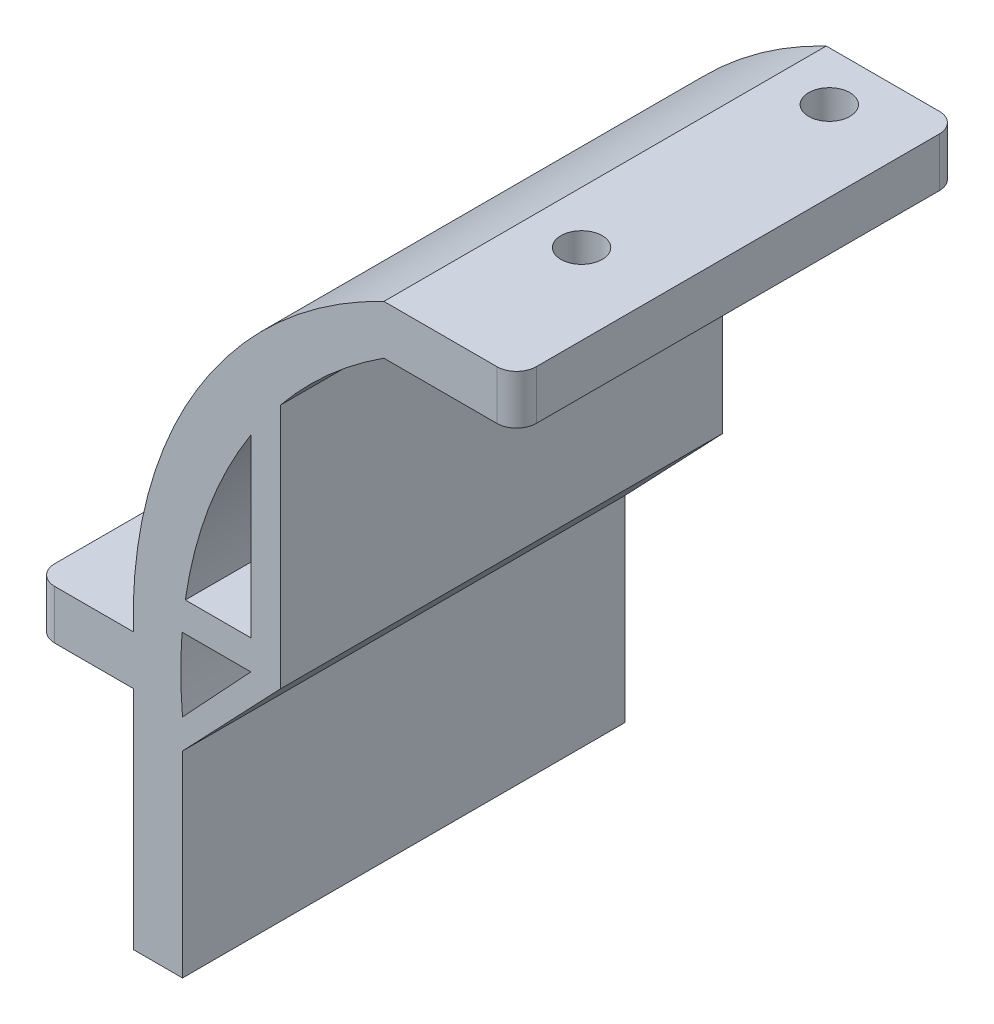
from build123d import *

# Parameters (mm, degrees)
SKETCH3_W           = 13.5
SKETCH3_H           = 5
SKETCH3_W_2         = 10
SKETCH3_W_3         = 5
SKETCH3_H_2         = 23
BOSS_EXTRUDE1_DEPTH = 45
FILLET1_R           = 2
SKETCH5_R           = 2.1
CUT_EXTRUDE2_DEPTH  = 45
SKETCH6_R           = 2.1
CUT_EXTRUDE3_DEPTH  = 45
SKETCH7_W           = 8.210459319
SKETCH7_H           = 32.58724939
BOSS_EXTRUDE2_DEPTH = 5
SKETCH8_R           = 2.1
CUT_EXTRUDE5_DEPTH  = 45
BOSS_EXTRUDE3_DEPTH = 45


with BuildPart() as part:
    # Sketch3 → Boss-Extrude1 (new body)
    with BuildSketch(Plane.XY):
        with BuildLine():
            ThreePointArc((-5.06519953, 257.264696919), (-21.146881422, 239.197551787), (-25.551614771, 215.414352888))
            Line((-25.551614771, 215.414352888), (-30.551614771, 215.414352888))
            Line((-30.551614771, 215.414352888), (-30.551614771, 220.414352888))
            ThreePointArc((-30.551614771, 220.414352888), (-24.004098535, 245.112635185), (-5.06519953, 262.264696919))
            Line((-5.06519953, 262.264696919), (-5.06519953, 257.264696919))
        make_face()
        with Locations((1.68480047, 259.764696919)):
            Rectangle(SKETCH3_W, SKETCH3_H)
        with Locations((-35.551614771, 217.914352888)):
            Rectangle(SKETCH3_W_2, SKETCH3_H)
        with Locations((-28.051614771, 203.914352888)):
            Rectangle(SKETCH3_W_3, SKETCH3_H_2)
    extrude(amount=BOSS_EXTRUDE1_DEPTH)

    # Fillet1
    fillet1_edges = [part.edges().sort_by_distance(p)[0] for p in [
        (-40.551614771, 217.914352888, 0),
        (8.43480047, 259.764696919, 45),
        (8.43480047, 259.764696919, 0),
        (-40.551614771, 217.914352888, 45),
    ]]
    fillet(fillet1_edges, radius=FILLET1_R)

    # Sketch5 → Cut-Extrude2 (cut)
    with BuildSketch(Plane(origin=(0, 262.264696919, 0), x_dir=(1, 0, 0), z_dir=(0, 1, 0))):
        with Locations((0.24480047, -40)):
            Circle(SKETCH5_R)
        with Locations((0.24480047, -14.8)):
            Circle(SKETCH5_R)
    extrude(amount=-CUT_EXTRUDE2_DEPTH, mode=Mode.SUBTRACT)

    # Sketch6 → Cut-Extrude3 (cut)
    with BuildSketch(Plane(origin=(0, 220.414352888, 0), x_dir=(1, 0, 0), z_dir=(0, 1, 0))):
        with Locations((-35.551614771, -10)):
            Circle(SKETCH6_R)
        with Locations((-35.551614771, -35)):
            Circle(SKETCH6_R)
    extrude(amount=-CUT_EXTRUDE3_DEPTH, mode=Mode.SUBTRACT)

    # Sketch7 → Boss-Extrude2 (add)
    with BuildSketch(Plane(origin=(0, 262.264696919, 0), x_dir=(1, 0, 0), z_dir=(0, 1, 0))):
        with Locations((1.09445166, -26.923464517)):
            Rectangle(SKETCH7_W, SKETCH7_H)
    extrude(amount=-BOSS_EXTRUDE2_DEPTH)

    # Sketch8 → Cut-Extrude5 (cut)
    with BuildSketch(Plane(origin=(0, 262.264696919, 0), x_dir=(1, 0, 0), z_dir=(0, 1, 0))):
        with Locations((0.24480047, -5)):
            Circle(SKETCH8_R)
        with Locations((0.24480047, -30.2)):
            Circle(SKETCH8_R)
    extrude(amount=-CUT_EXTRUDE5_DEPTH, mode=Mode.SUBTRACT)

    # Sketch9 → Boss-Extrude3 (add, through all)
    with BuildSketch(Plane.XY.offset(45)):
        with BuildLine():
            ThreePointArc((-25.265361734, 225.859750777), (-25.456525287, 224.362535182), (-25.597369426, 222.859750777))
            Line((-25.597369426, 222.859750777), (-18.597369426, 222.859750777))
            Line((-18.597369426, 222.859750777), (-15.597369426, 222.859750777))
            Line((-15.597369426, 222.859750777), (-15.597369426, 247.859750777))
            ThreePointArc((-15.597369426, 247.859750777), (-17.156118075, 245.834377519), (-18.597369426, 243.72377838))
            Line((-18.597369426, 243.72377838), (-18.597369426, 225.859750777))
            Line((-18.597369426, 225.859750777), (-25.265361734, 225.859750777))
        make_face()
        Polygon((-15.597369426, 222.859750777), (-18.597369426, 222.859750777), (-25.551614771, 215.414352888), (-25.551614771, 212.414352888), align=None)
    extrude(amount=-BOSS_EXTRUDE3_DEPTH)


solid = part.part
